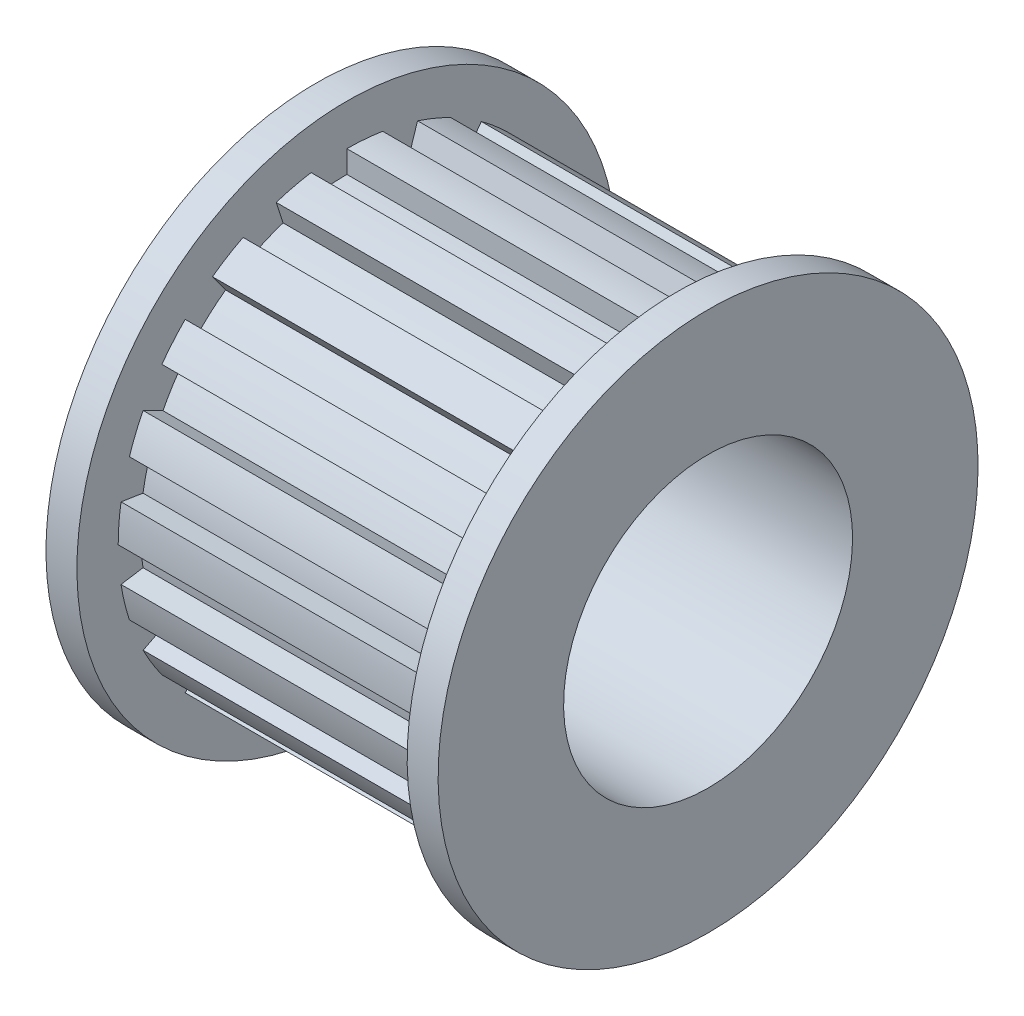
from build123d import *

# Parameters (mm, degrees)
SKETCH_7_R          = 7
CUT_EXTRUDE_3_DEPTH = 10
CUT_EXTRUDE_4_DEPTH = 8


with BuildPart() as part:
    # 草图1 → 旋转1 (revolve)
    with BuildSketch(Plane.XY):
        Polygon((-9.5, 0), (9.5, 0), (9.5, 13.08), (8, 13.08), (8, 11.08), (-8, 11.08), (-8, 13.08), (-9.5, 13.08), align=None)
    revolve(axis=Axis((-9.5, 0, 0), (1, 0, 0)))

    # 草图7 → 切除-拉伸3 (cut, symmetric)
    with BuildSketch(Plane(origin=(0, 0, 0), x_dir=(0, 0, -1), z_dir=(1, 0, 0))):
        Circle(SKETCH_7_R)
    extrude(amount=CUT_EXTRUDE_3_DEPTH, both=True, mode=Mode.SUBTRACT)

    # 草图2 → 切除-拉伸4 (cut, symmetric)
    with BuildSketch(Plane(origin=(0, 0, 0), x_dir=(0, 0, -1), z_dir=(1, 0, 0))):
        with BuildLine():
            Line((10, 0), (11.08, 0))
            ThreePointArc((11.08, 0), (11.045844058, 0.869326781), (10.943586814, 1.733293873))
            Line((10.943586814, 1.733293873), (9.876883406, 1.56434465))
            ThreePointArc((9.876883406, 1.56434465), (9.969173337, 0.784590957), (10, 0))
        make_face()
        with BuildLine():
            Line((9.510565163, -3.090169944), (10.537706201, -3.423908298))
            ThreePointArc((10.537706201, -3.423908298), (10.773858718, -2.586574632), (10.943586814, -1.733293873))
            Line((10.943586814, -1.733293873), (9.876883406, -1.56434465))
            ThreePointArc((9.876883406, -1.56434465), (9.723699204, -2.334453639), (9.510565163, -3.090169944))
        make_face()
        with BuildLine():
            Line((8.090169944, -5.877852523), (8.963908298, -6.512660595))
            ThreePointArc((8.963908298, -6.512660595), (9.447253021, -5.789284097), (9.872352288, -5.030214737))
            Line((9.872352288, -5.030214737), (8.910065242, -4.539904997))
            ThreePointArc((8.910065242, -4.539904997), (8.526401644, -5.224985647), (8.090169944, -5.877852523))
        make_face()
        with BuildLine():
            Line((5.877852523, -8.090169944), (6.512660595, -8.963908298))
            ThreePointArc((6.512660595, -8.963908298), (7.195884375, -8.425298099), (7.834743136, -7.834743136))
            Line((7.834743136, -7.834743136), (7.071067812, -7.071067812))
            ThreePointArc((7.071067812, -7.071067812), (6.494480483, -7.604059656), (5.877852523, -8.090169944))
        make_face()
        with BuildLine():
            Line((3.090169944, -9.510565163), (3.423908298, -10.537706201))
            ThreePointArc((3.423908298, -10.537706201), (4.240132431, -10.23658522), (5.030214737, -9.872352288))
            Line((5.030214737, -9.872352288), (4.539904997, -8.910065242))
            ThreePointArc((4.539904997, -8.910065242), (3.826834324, -9.238795325), (3.090169944, -9.510565163))
        make_face()
        with BuildLine():
            Line((0, -10), (0, -11.08))
            ThreePointArc((0, -11.08), (0.869326781, -11.045844058), (1.733293873, -10.943586814))
            Line((1.733293873, -10.943586814), (1.56434465, -9.876883406))
            ThreePointArc((1.56434465, -9.876883406), (0.784590957, -9.969173337), (0, -10))
        make_face()
        with BuildLine():
            Line((-3.090169944, -9.510565163), (-3.423908298, -10.537706201))
            ThreePointArc((-3.423908298, -10.537706201), (-2.586574632, -10.773858718), (-1.733293873, -10.943586814))
            Line((-1.733293873, -10.943586814), (-1.56434465, -9.876883406))
            ThreePointArc((-1.56434465, -9.876883406), (-2.334453639, -9.723699204), (-3.090169944, -9.510565163))
        make_face()
        with BuildLine():
            Line((-5.877852523, -8.090169944), (-6.512660595, -8.963908298))
            ThreePointArc((-6.512660595, -8.963908298), (-5.789284097, -9.447253021), (-5.030214737, -9.872352288))
            Line((-5.030214737, -9.872352288), (-4.539904997, -8.910065242))
            ThreePointArc((-4.539904997, -8.910065242), (-5.224985647, -8.526401644), (-5.877852523, -8.090169944))
        make_face()
        with BuildLine():
            Line((-8.090169944, -5.877852523), (-8.963908298, -6.512660595))
            ThreePointArc((-8.963908298, -6.512660595), (-8.425298099, -7.195884375), (-7.834743136, -7.834743136))
            Line((-7.834743136, -7.834743136), (-7.071067812, -7.071067812))
            ThreePointArc((-7.071067812, -7.071067812), (-7.604059656, -6.494480483), (-8.090169944, -5.877852523))
        make_face()
        with BuildLine():
            Line((-9.510565163, -3.090169944), (-10.537706201, -3.423908298))
            ThreePointArc((-10.537706201, -3.423908298), (-10.23658522, -4.240132431), (-9.872352288, -5.030214737))
            Line((-9.872352288, -5.030214737), (-8.910065242, -4.539904997))
            ThreePointArc((-8.910065242, -4.539904997), (-9.238795325, -3.826834324), (-9.510565163, -3.090169944))
        make_face()
        with BuildLine():
            Line((-10, 0), (-11.08, 0))
            ThreePointArc((-11.08, 0), (-11.045844058, -0.869326781), (-10.943586814, -1.733293873))
            Line((-10.943586814, -1.733293873), (-9.876883406, -1.56434465))
            ThreePointArc((-9.876883406, -1.56434465), (-9.969173337, -0.784590957), (-10, 0))
        make_face()
        with BuildLine():
            Line((-9.510565163, 3.090169944), (-10.537706201, 3.423908298))
            ThreePointArc((-10.537706201, 3.423908298), (-10.773858718, 2.586574632), (-10.943586814, 1.733293873))
            Line((-10.943586814, 1.733293873), (-9.876883406, 1.56434465))
            ThreePointArc((-9.876883406, 1.56434465), (-9.723699204, 2.334453639), (-9.510565163, 3.090169944))
        make_face()
        with BuildLine():
            Line((-8.090169944, 5.877852523), (-8.963908298, 6.512660595))
            ThreePointArc((-8.963908298, 6.512660595), (-9.447253021, 5.789284097), (-9.872352288, 5.030214737))
            Line((-9.872352288, 5.030214737), (-8.910065242, 4.539904997))
            ThreePointArc((-8.910065242, 4.539904997), (-8.526401644, 5.224985647), (-8.090169944, 5.877852523))
        make_face()
        with BuildLine():
            Line((-5.877852523, 8.090169944), (-6.512660595, 8.963908298))
            ThreePointArc((-6.512660595, 8.963908298), (-7.195884375, 8.425298099), (-7.834743136, 7.834743136))
            Line((-7.834743136, 7.834743136), (-7.071067812, 7.071067812))
            ThreePointArc((-7.071067812, 7.071067812), (-6.494480483, 7.604059656), (-5.877852523, 8.090169944))
        make_face()
        with BuildLine():
            Line((-3.090169944, 9.510565163), (-3.423908298, 10.537706201))
            ThreePointArc((-3.423908298, 10.537706201), (-4.240132431, 10.23658522), (-5.030214737, 9.872352288))
            Line((-5.030214737, 9.872352288), (-4.539904997, 8.910065242))
            ThreePointArc((-4.539904997, 8.910065242), (-3.826834324, 9.238795325), (-3.090169944, 9.510565163))
        make_face()
        with BuildLine():
            Line((0, 10), (0, 11.08))
            ThreePointArc((0, 11.08), (-0.869326781, 11.045844058), (-1.733293873, 10.943586814))
            Line((-1.733293873, 10.943586814), (-1.56434465, 9.876883406))
            ThreePointArc((-1.56434465, 9.876883406), (-0.784590957, 9.969173337), (0, 10))
        make_face()
        with BuildLine():
            Line((3.090169944, 9.510565163), (3.423908298, 10.537706201))
            ThreePointArc((3.423908298, 10.537706201), (2.586574632, 10.773858718), (1.733293873, 10.943586814))
            Line((1.733293873, 10.943586814), (1.56434465, 9.876883406))
            ThreePointArc((1.56434465, 9.876883406), (2.334453639, 9.723699204), (3.090169944, 9.510565163))
        make_face()
        with BuildLine():
            Line((5.877852523, 8.090169944), (6.512660595, 8.963908298))
            ThreePointArc((6.512660595, 8.963908298), (5.789284097, 9.447253021), (5.030214737, 9.872352288))
            Line((5.030214737, 9.872352288), (4.539904997, 8.910065242))
            ThreePointArc((4.539904997, 8.910065242), (5.224985647, 8.526401644), (5.877852523, 8.090169944))
        make_face()
        with BuildLine():
            Line((8.090169944, 5.877852523), (8.963908298, 6.512660595))
            ThreePointArc((8.963908298, 6.512660595), (8.425298099, 7.195884375), (7.834743136, 7.834743136))
            Line((7.834743136, 7.834743136), (7.071067812, 7.071067812))
            ThreePointArc((7.071067812, 7.071067812), (7.604059656, 6.494480483), (8.090169944, 5.877852523))
        make_face()
        with BuildLine():
            Line((9.510565163, 3.090169944), (10.537706201, 3.423908298))
            ThreePointArc((10.537706201, 3.423908298), (10.23658522, 4.240132431), (9.872352288, 5.030214737))
            Line((9.872352288, 5.030214737), (8.910065242, 4.539904997))
            ThreePointArc((8.910065242, 4.539904997), (9.238795325, 3.826834324), (9.510565163, 3.090169944))
        make_face()
    extrude(amount=CUT_EXTRUDE_4_DEPTH, both=True, mode=Mode.SUBTRACT)


solid = part.part
